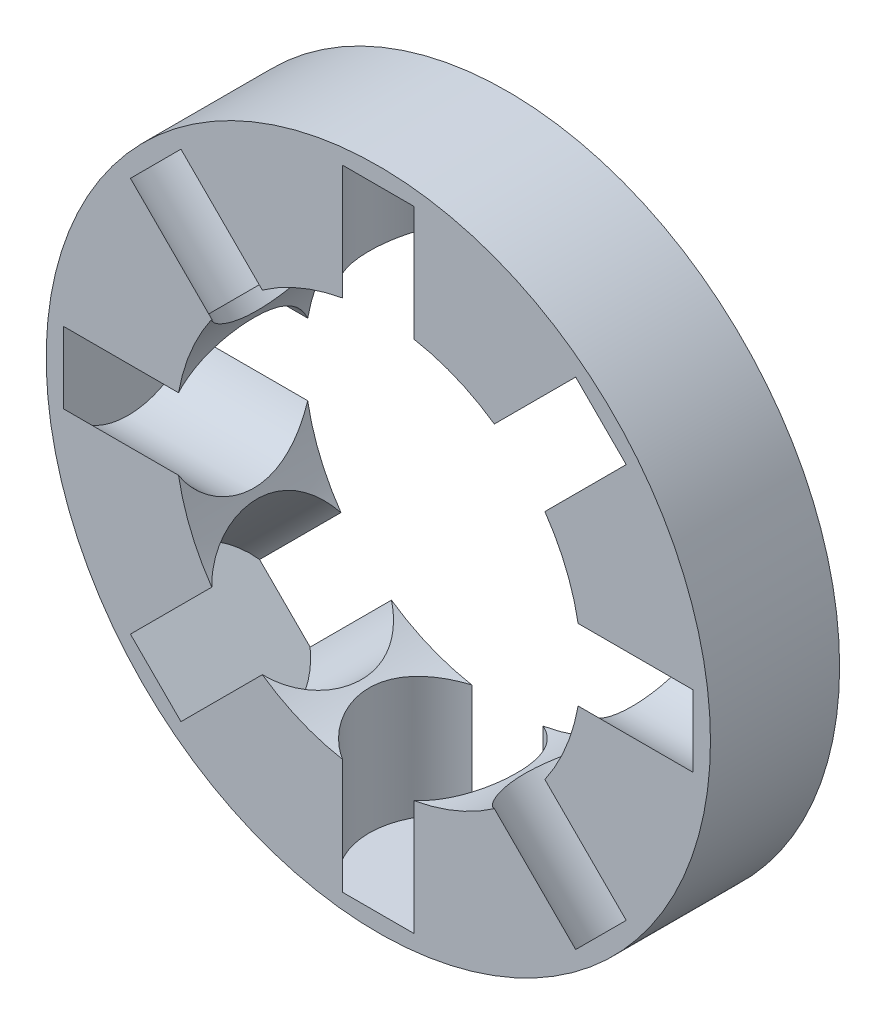
from build123d import *

# Parameters (mm, degrees)
SKETCH1_R                   = 18
SKETCH1_R_2                 = 11
BOSS_EXTRUDE1_DEPTH         = 3.5
SKETCH4_R                   = 4
CUT_EXTRUDE1_DEPTH          = 6.9
CIRPATTERN1_COUNT           = 8
SKETCH5_R                   = 4
SPACECLAIM_FOR_MAGNET_DEPTH = 6


with BuildPart() as part:
    # Sketch1 → Boss-Extrude1 (new, symmetric)
    with BuildSketch(Plane.XY):
        Circle(SKETCH1_R)
        Circle(SKETCH1_R_2, mode=Mode.SUBTRACT)
    extrude(amount=BOSS_EXTRUDE1_DEPTH, both=True)

    # Sketch4 → Cut-Extrude1 (cut)
    with BuildSketch(Plane(origin=(-10.162674858, 0, 0), x_dir=(0, 0, -1), z_dir=(1, 0, 0))):
        Circle(SKETCH4_R)
    cut_extrude1 = extrude(amount=-CUT_EXTRUDE1_DEPTH, mode=Mode.SUBTRACT)

    # CirPattern1: Cut-Extrude1 ×8 about axis
    cirpattern1_axis = Axis((0, 0, 3.5), (0, 0, -1))
    for i in range(1, CIRPATTERN1_COUNT):
        add(cut_extrude1.rotate(cirpattern1_axis, i * 360 / CIRPATTERN1_COUNT), mode=Mode.SUBTRACT)

    # Sketch5 → SpaceClaim for Magnet (add)
    with BuildSketch(Plane(origin=(-12.065133097, 12.065133097, 0), x_dir=(0.7071067811865487, 0.7071067811865465, 0), z_dir=(0.7071067811865465, -0.7071067811865487, 0))):
        Circle(SKETCH5_R)
    extrude(amount=SPACECLAIM_FOR_MAGNET_DEPTH)


solid = part.part
